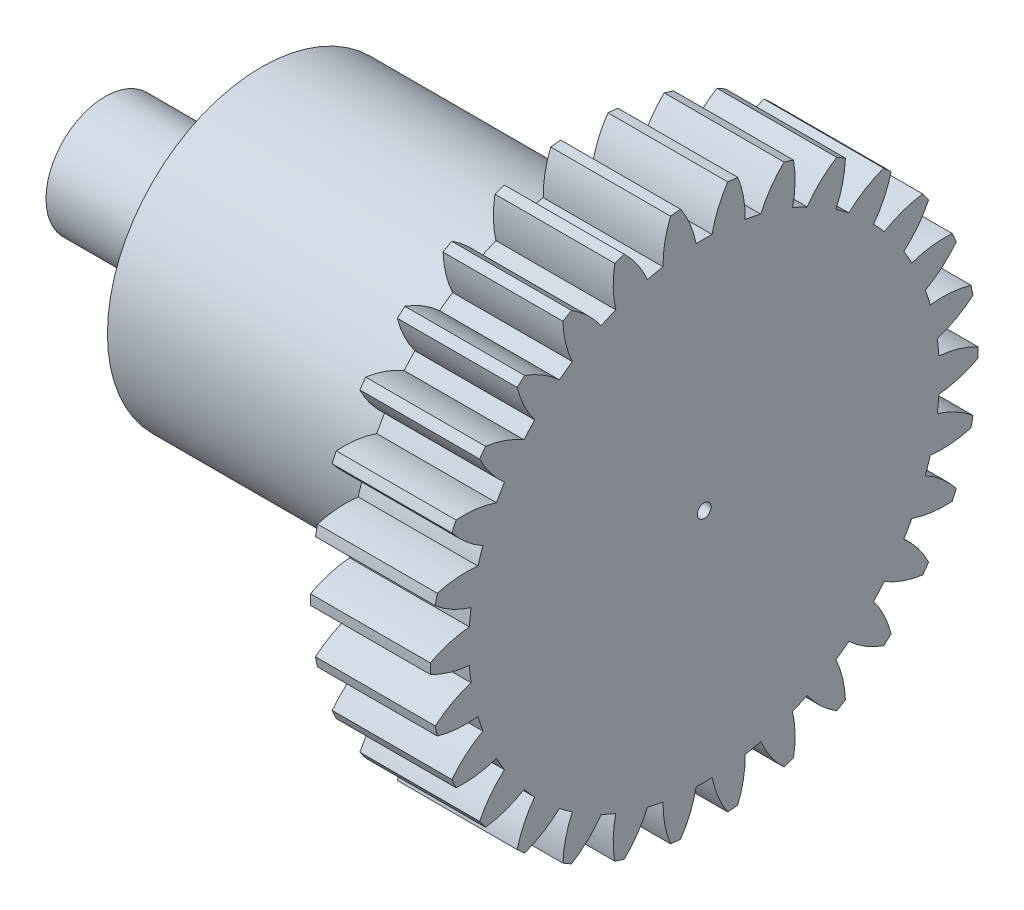
from build123d import *

# Parameters (mm, degrees)
BASPROSKE_W         = 7
BASPROSKE_H         = 16
TOOTHCUT_DEPTH      = 24.685438565
TEETHCUTS_COUNT     = 30
TEETHCUTS_ANGLE     = 348
BORSKE_R            = 0.4
BORE_DEPTH          = 50.0000508
SKETCH1_R           = 9
BOSS_EXTRUDE1_DEPTH = 19
SKETCH2_R           = 3.45
BOSS_EXTRUDE2_DEPTH = 9


with BuildPart() as part:
    # BasProSke → Base-Revolve (revolve)
    with BuildSketch(Plane(origin=(0, 0, 0), x_dir=(1, 0, 0), z_dir=(0, 1, 0)), mode=Mode.PRIVATE) as base_revolve_sk:
        with Locations((3.5, 8)):
            Rectangle(BASPROSKE_W, BASPROSKE_H)
    revolve(base_revolve_sk.sketch.rotate(Axis((-10, 0, 0), (1, 0, 0)), 180), axis=Axis((-10, 0, 0), (1, 0, 0)))

    # TooCutSke → ToothCut (cut, through all)
    with BuildSketch(Plane(origin=(0, 0, 0), x_dir=(0, 0, -1), z_dir=(1, 0, 0))):
        with BuildLine():
            ThreePointArc((0.466400716, 13.741086979), (0, 13.749), (-0.466400716, 13.741086979))
            ThreePointArc((-0.466400716, 13.741086979), (-0.819142092, 14.899954875), (-1.3974676, 15.964351834))
            ThreePointArc((-1.3974676, 15.964351834), (0, 16.0254), (1.3974676, 15.964351834))
            ThreePointArc((1.3974676, 15.964351834), (0.819142092, 14.899954875), (0.466400716, 13.741086979))
        make_face()
    toothcut = extrude(amount=TOOTHCUT_DEPTH, mode=Mode.SUBTRACT)

    # TeethCuts: ToothCut ×30 about axis
    teethcuts_axis = Axis((-10, 0, 0), (1, 0, 0))
    for i in range(1, TEETHCUTS_COUNT):
        add(toothcut.rotate(teethcuts_axis, i * TEETHCUTS_ANGLE / (TEETHCUTS_COUNT - 1)), mode=Mode.SUBTRACT)

    # BorSke → Bore (cut, symmetric)
    with BuildSketch(Plane(origin=(0, 0, 0), x_dir=(0, 0, -1), z_dir=(1, 0, 0))):
        with Locations(Location((0, 0, 0), (0, 0, 180))):
            Circle(BORSKE_R)
    extrude(amount=BORE_DEPTH, both=True, mode=Mode.SUBTRACT)

    # Sketch1 → Boss-Extrude1 (add)
    with BuildSketch(Plane.ZY):
        with Locations(Location((-0.138271535, 0.375341155, 0), (0, 0, 180))):
            Circle(SKETCH1_R)
    extrude(amount=BOSS_EXTRUDE1_DEPTH)

    # Sketch2 → Boss-Extrude2 (add)
    with BuildSketch(Plane.ZY.offset(19)):
        Circle(SKETCH2_R)
    extrude(amount=BOSS_EXTRUDE2_DEPTH)


solid = part.part
